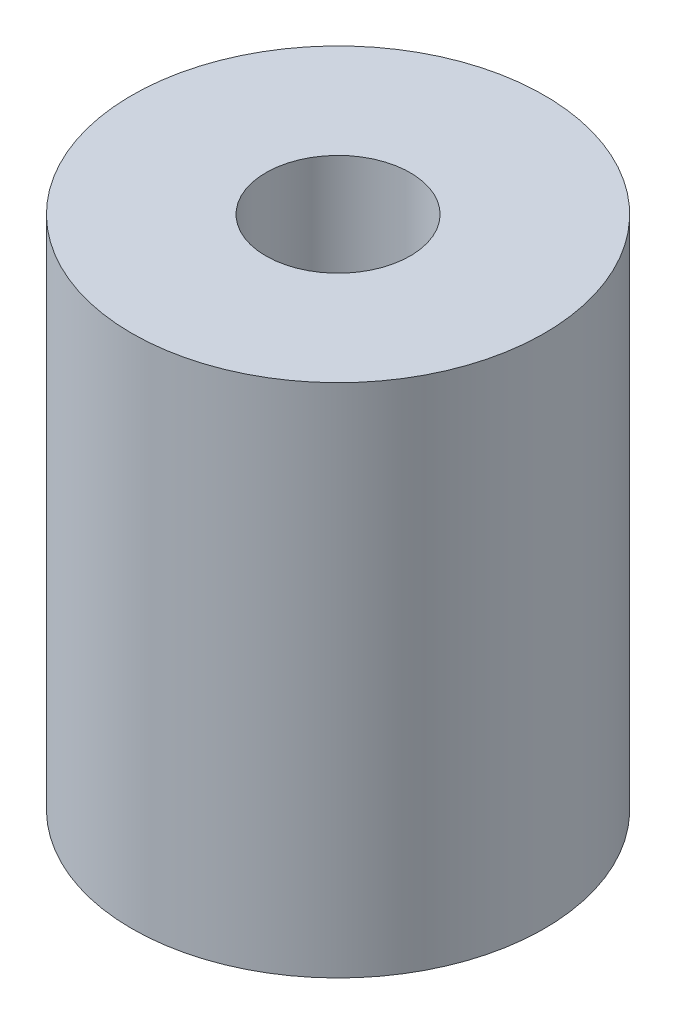
from build123d import *

# Parameters (mm, degrees)
SKETCH1_R           = 5.08
SKETCH1_R_2         = 1.778
BOSS_EXTRUDE1_DEPTH = 12.7


with BuildPart() as part:
    # Sketch1 → Boss-Extrude1 (new body)
    with BuildSketch(Plane(origin=(0, 0, 0), x_dir=(1, 0, 0), z_dir=(0, 1, 0))):
        Circle(SKETCH1_R)
        Circle(SKETCH1_R_2, mode=Mode.SUBTRACT)
    extrude(amount=BOSS_EXTRUDE1_DEPTH)


solid = part.part
